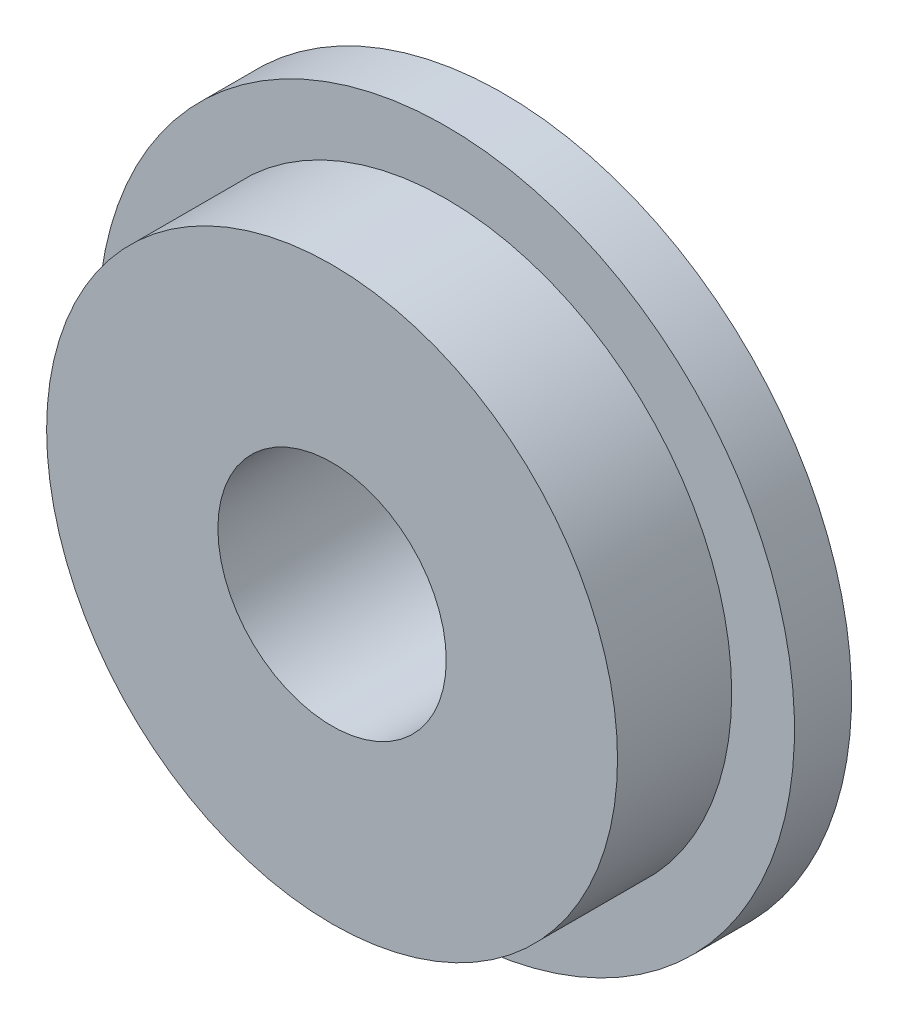
from build123d import *

# Parameters (mm, degrees)
SKETCH_1_R               = 2.5
EXTRUDE_1_DEPTH          = 1.5
SKETCH_3_R               = 3.05
EXTRUDE_2_DEPTH          = 0.5
SKETCH_4_R               = 1
CUT_EXTRUDE_1_DEPTH      = 1
CUT_EXTRUDE_1_DEPTH_BACK = 2.5


with BuildPart() as part:
    # Эскиз1 → Бобышка-Вытянуть1 (new body)
    with BuildSketch(Plane.XY):
        Circle(SKETCH_1_R)
    extrude(amount=EXTRUDE_1_DEPTH)

    # Эскиз3 → Бобышка-Вытянуть2 (add)
    with BuildSketch(Plane(origin=(0, 0, 0), x_dir=(-1, 0, 0), z_dir=(0, 0, -1))):
        Circle(SKETCH_3_R)
    extrude(amount=-EXTRUDE_2_DEPTH)

    # Эскиз4 → Вырез-Вытянуть1 (cut, two sides)
    with BuildSketch(Plane.XY.offset(1.5)) as cut_extrude_1_sk:
        Circle(SKETCH_4_R)
    extrude(amount=CUT_EXTRUDE_1_DEPTH, mode=Mode.SUBTRACT)
    extrude(cut_extrude_1_sk.sketch, amount=-CUT_EXTRUDE_1_DEPTH_BACK, mode=Mode.SUBTRACT)


solid = part.part
